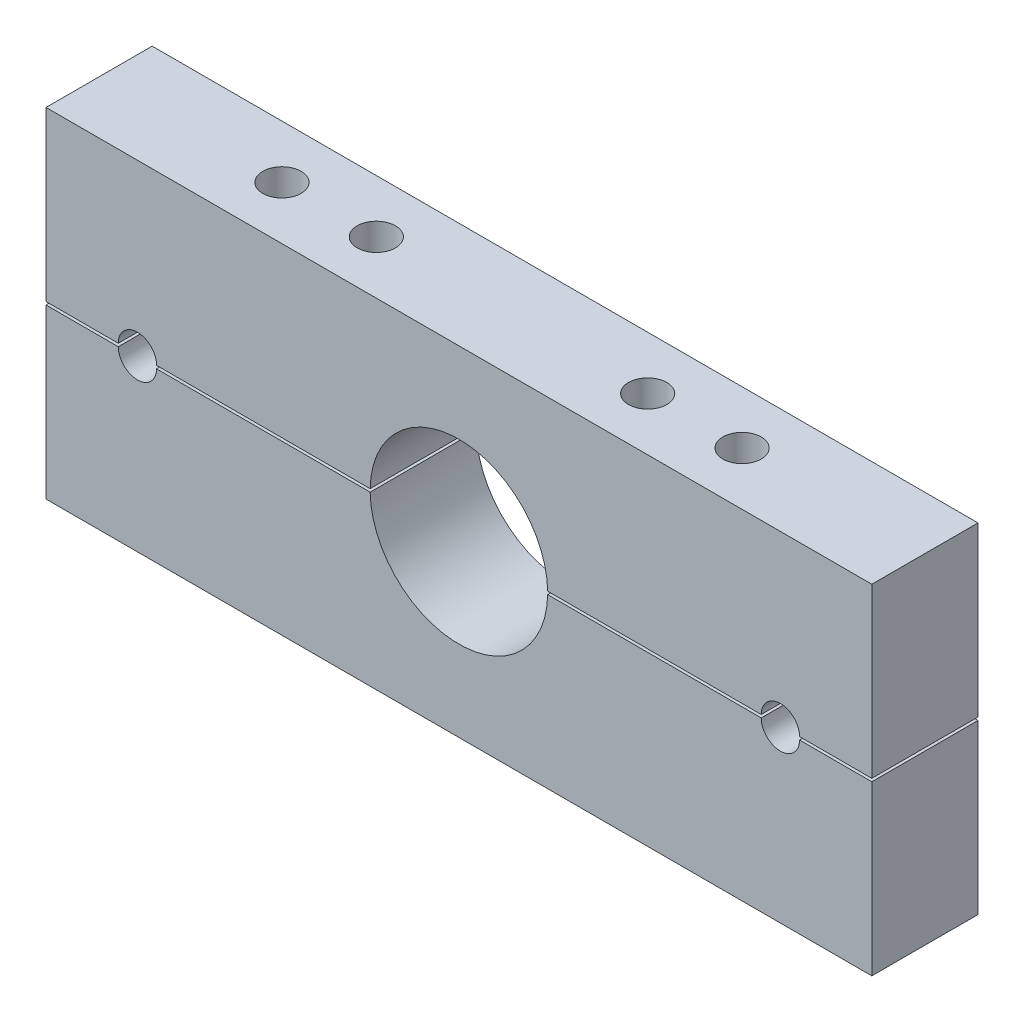
from build123d import *

# Parameters (mm, degrees)
BOSS_EXTRUDE1_DEPTH = 36
SKETCH4_R           = 6.5
CUT_EXTRUDE3_DEPTH  = 58.5
SKETCH5_W           = 36
SKETCH5_H           = 1
CUT_EXTRUDE5_DEPTH  = 281
CUT_EXTRUDE6_DEPTH  = 37


with BuildPart() as part:
    # Sketch1 → Boss-Extrude1 (new body)
    with BuildSketch(Plane.XY):
        with BuildLine():
            Line((267.829500207, -84.51965646), (-12.170499793, -84.51965646))
            Line((-12.170499793, -84.51965646), (-12.170499793, -142.01965646))
            Line((-12.170499793, -142.01965646), (97.729500207, -142.01965646))
            ThreePointArc((97.729500207, -142.01965646), (127.829500207, -111.91965646), (157.929500207, -142.01965646))
            Line((157.929500207, -142.01965646), (267.829500207, -142.01965646))
            Line((267.829500207, -142.01965646), (267.829500207, -84.51965646))
        make_face()
    boss_extrude1 = extrude(amount=BOSS_EXTRUDE1_DEPTH)

    # Sketch4 → Cut-Extrude3 (cut, through all)
    with BuildSketch(Plane(origin=(0, -84.51965646, 0), x_dir=(1, 0, 0), z_dir=(0, 1, 0))):
        with Locations((205.829500207, -18)):
            Circle(SKETCH4_R)
        with Locations((173.829500207, -18)):
            Circle(SKETCH4_R)
        with Locations((81.829500207, -18)):
            Circle(SKETCH4_R)
        with Locations((49.829500207, -18)):
            Circle(SKETCH4_R)
    cut_extrude3 = extrude(amount=-CUT_EXTRUDE3_DEPTH, mode=Mode.SUBTRACT)

    # Mirror1: Boss-Extrude1, Cut-Extrude3 across plane
    add(boss_extrude1.mirror(Plane(origin=(0, -142.01965646, 36), x_dir=(0, 0, 1), z_dir=(0, 1, 0))))
    add(cut_extrude3.mirror(Plane(origin=(0, -142.01965646, 36), x_dir=(0, 0, 1), z_dir=(0, 1, 0))), mode=Mode.SUBTRACT)

    # Sketch5 → Cut-Extrude5 (cut, through all)
    with BuildSketch(Plane.ZY.offset(12.170499793)):
        with Locations((18, -142.01965646)):
            Rectangle(SKETCH5_W, SKETCH5_H)
    extrude(amount=-CUT_EXTRUDE5_DEPTH, mode=Mode.SUBTRACT)

    # Sketch3 → Cut-Extrude6 (cut, through all)
    with BuildSketch(Plane.XY.offset(36)):
        with BuildLine():
            ThreePointArc((25.329500207, -141.51965646), (18.829500207, -135.01965646), (12.329500207, -141.51965646))
            Line((12.329500207, -141.51965646), (25.329500207, -141.51965646))
        make_face()
        with BuildLine():
            Line((25.329500207, -142.51965646), (12.329500207, -142.51965646))
            ThreePointArc((12.329500207, -142.51965646), (18.829500207, -149.01965646), (25.329500207, -142.51965646))
        make_face()
        with BuildLine():
            ThreePointArc((243.329500207, -141.51965646), (236.829500207, -135.01965646), (230.329500207, -141.51965646))
            Line((230.329500207, -141.51965646), (243.329500207, -141.51965646))
        make_face()
        with BuildLine():
            Line((243.329500207, -142.51965646), (230.329500207, -142.51965646))
            ThreePointArc((230.329500207, -142.51965646), (236.829500207, -149.01965646), (243.329500207, -142.51965646))
        make_face()
    extrude(amount=-CUT_EXTRUDE6_DEPTH, mode=Mode.SUBTRACT)


solid = part.part
